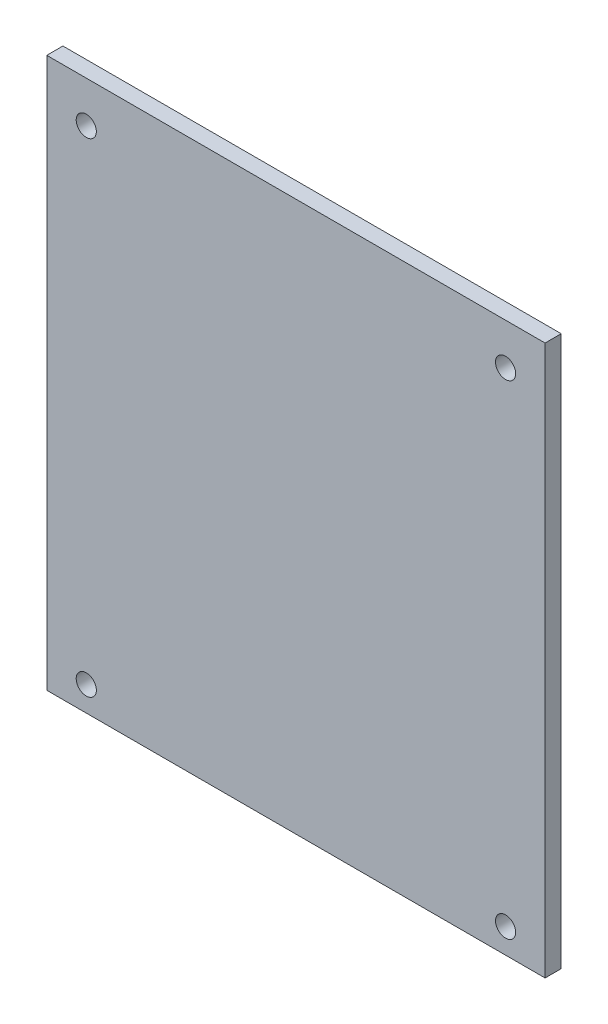
from build123d import *

# Parameters (mm, degrees)
SKETCH1_W           = 78.486
SKETCH1_H           = 86.614
BOSS_EXTRUDE1_DEPTH = 2.54
SKETCH2_R           = 1.5875
CUT_EXTRUDE1_DEPTH  = 2.54


with BuildPart() as part:
    # Sketch1 → Boss-Extrude1 (new body)
    with BuildSketch(Plane.XY):
        with Locations((39.243, 43.307)):
            Rectangle(SKETCH1_W, SKETCH1_H)
    extrude(amount=BOSS_EXTRUDE1_DEPTH)

    # Sketch2 → Cut-Extrude1 (cut)
    with BuildSketch(Plane.XY.offset(2.54)):
        with Locations((6.223, 80.1116)):
            Circle(SKETCH2_R)
        with Locations((72.263, 80.1116)):
            Circle(SKETCH2_R)
        with Locations((72.263, 3.9116)):
            Circle(SKETCH2_R)
        with Locations((6.223, 3.9116)):
            Circle(SKETCH2_R)
    extrude(amount=-CUT_EXTRUDE1_DEPTH, mode=Mode.SUBTRACT)


solid = part.part
